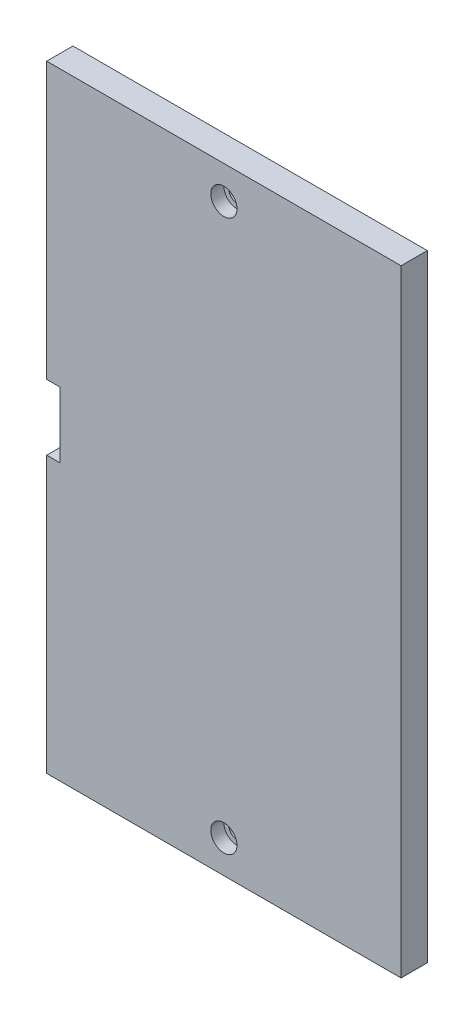
from build123d import *

# Parameters (mm, degrees)
SKETCH1_W           = 54
SKETCH1_H           = 94
BOSS_EXTRUDE1_DEPTH = 4
CUT_EXTRUDE1_REACH  = 6
SKETCH2_W           = 2
SKETCH2_H           = 10
SKETCH3_R           = 1.25
CUT_EXTRUDE2_DEPTH  = 5
CHAMFER1_SIZE       = 1
SKETCH4_R           = 2
CUT_EXTRUDE3_DEPTH  = 2


with BuildPart() as part:
    # Sketch1 → Boss-Extrude1 (new body)
    with BuildSketch(Plane.XY):
        with Locations((27, 47)):
            Rectangle(SKETCH1_W, SKETCH1_H)
    extrude(amount=BOSS_EXTRUDE1_DEPTH)

    # Sketch2 → Cut-Extrude1 (cut, up to next)
    with BuildSketch(Plane.XY.offset(4), mode=Mode.PRIVATE) as cut_extrude1_sk1:
        with Locations((1, 47)):
            Rectangle(SKETCH2_W, SKETCH2_H)
    cut_extrude1_tool1 = extrude(cut_extrude1_sk1.sketch, amount=-CUT_EXTRUDE1_REACH, mode=Mode.PRIVATE) & part.part
    add(cut_extrude1_tool1.solids().sort_by_distance((1, 47, 4))[0], mode=Mode.SUBTRACT)

    # Sketch3 → Cut-Extrude2 (cut, through all)
    with BuildSketch(Plane.XY.offset(4)):
        with Locations((27, 89)):
            Circle(SKETCH3_R)
        with Locations((27, 5)):
            Circle(SKETCH3_R)
    extrude(amount=-CUT_EXTRUDE2_DEPTH, mode=Mode.SUBTRACT)

    # Chamfer1
    chamfer1_edges = [part.edges().sort_by_distance(p)[0] for p in [
        (2, 47, 0),
    ]]
    chamfer(chamfer1_edges, length=CHAMFER1_SIZE)

    # Sketch4 → Cut-Extrude3 (cut)
    with BuildSketch(Plane.XY.offset(4)):
        with Locations((27, 89)):
            Circle(SKETCH4_R)
        with Locations((27, 5)):
            Circle(SKETCH4_R)
    extrude(amount=-CUT_EXTRUDE3_DEPTH, mode=Mode.SUBTRACT)


solid = part.part
